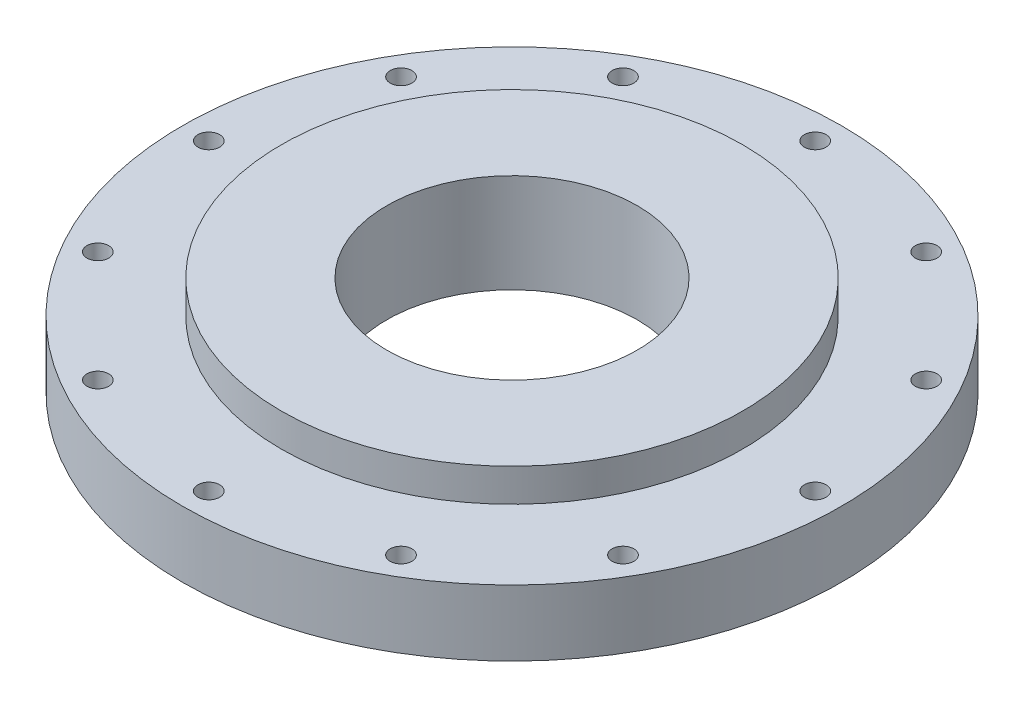
from build123d import *

# Parameters (mm, degrees)
SKETCH1_R               = 63.5
BOSS_EXTRUDE1_DEPTH     = 12.7
SKETCH2_R               = 44.45
BOSS_EXTRUDE2_DEPTH     = 6.35
SKETCH3_R               = 24.13
CUT_EXTRUDE1_DEPTH      = 1
CUT_EXTRUDE1_DEPTH_BACK = 20.05
SKETCH4_R               = 2.0955
CUT_EXTRUDE2_DEPTH      = 20.05


with BuildPart() as part:
    # Sketch1 → Boss-Extrude1 (new body)
    with BuildSketch(Plane(origin=(0, 0, 0), x_dir=(1, 0, 0), z_dir=(0, 1, 0))):
        Circle(SKETCH1_R)
    extrude(amount=BOSS_EXTRUDE1_DEPTH)

    # Sketch2 → Boss-Extrude2 (add)
    with BuildSketch(Plane(origin=(0, 12.7, 0), x_dir=(1, 0, 0), z_dir=(0, 1, 0))):
        Circle(SKETCH2_R)
    extrude(amount=BOSS_EXTRUDE2_DEPTH)

    # Sketch3 → Cut-Extrude1 (cut, two sides)
    with BuildSketch(Plane(origin=(0, 19.05, 0), x_dir=(1, 0, 0), z_dir=(0, 1, 0))) as cut_extrude1_sk:
        Circle(SKETCH3_R)
    extrude(amount=CUT_EXTRUDE1_DEPTH, mode=Mode.SUBTRACT)
    extrude(cut_extrude1_sk.sketch, amount=-CUT_EXTRUDE1_DEPTH_BACK, mode=Mode.SUBTRACT)

    # Sketch4 → Cut-Extrude2 (cut, through all)
    with BuildSketch(Plane.XZ):
        with Locations((0, -58.42)):
            Circle(SKETCH4_R)
        with Locations((-29.21, -50.593204089)):
            Circle(SKETCH4_R)
        with Locations((-50.593204089, -29.21)):
            Circle(SKETCH4_R)
        with Locations((-58.42, 0)):
            Circle(SKETCH4_R)
        with Locations((-50.593204089, 29.21)):
            Circle(SKETCH4_R)
        with Locations((-29.21, 50.593204089)):
            Circle(SKETCH4_R)
        with Locations((0, 58.42)):
            Circle(SKETCH4_R)
        with Locations((29.21, 50.593204089)):
            Circle(SKETCH4_R)
        with Locations((50.593204089, 29.21)):
            Circle(SKETCH4_R)
        with Locations((58.42, 0)):
            Circle(SKETCH4_R)
        with Locations((50.593204089, -29.21)):
            Circle(SKETCH4_R)
        with Locations((29.21, -50.593204089)):
            Circle(SKETCH4_R)
    extrude(amount=-CUT_EXTRUDE2_DEPTH, mode=Mode.SUBTRACT)


solid = part.part
